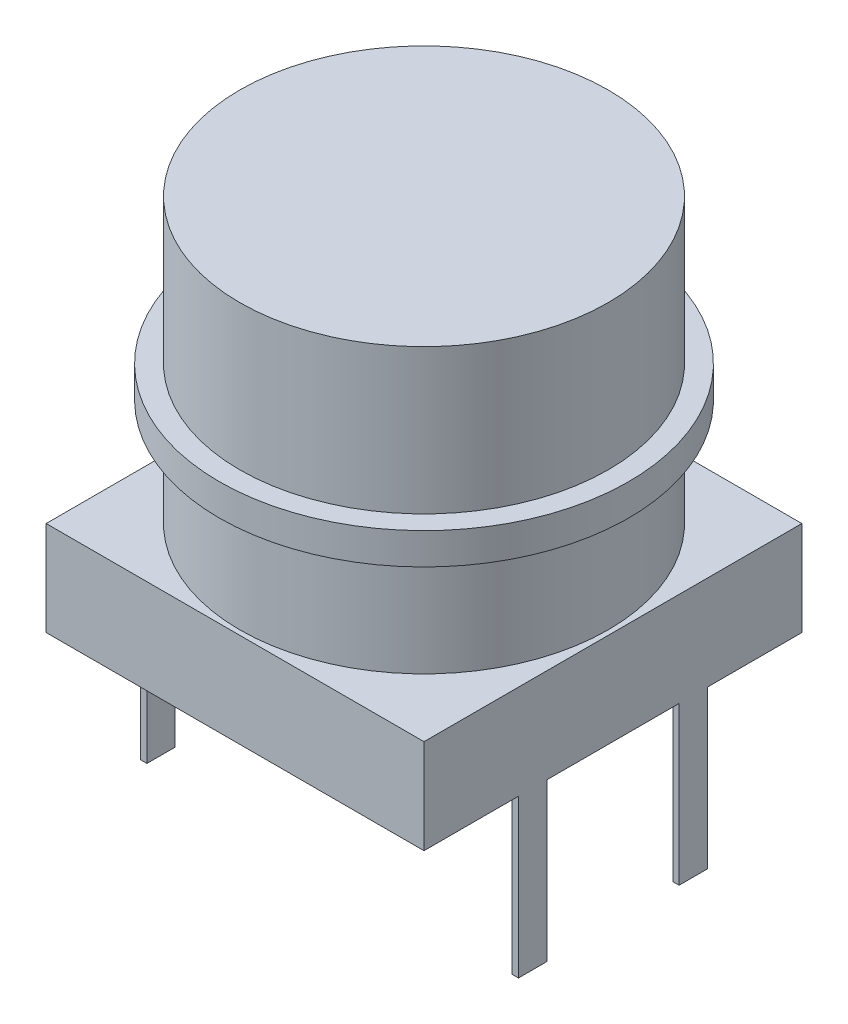
from build123d import *

# Parameters (mm, degrees)
SKETCH_1_W      = 12
SKETCH_1_H      = 12
EXTRUDE_1_DEPTH = 3
SKETCH_2_W      = 5
SKETCH_2_H      = 5
EXTRUDE_2_DEPTH = 3.4
SKETCH_3_R      = 6.5
EXTRUDE_3_DEPTH = 1
EXTRUDE_START   = -7.4
SKETCH_4_R      = 5.85
EXTRUDE_4_DEPTH = 12
SKETCH_5_W      = 0.2
SKETCH_5_H      = 0.9
EXTRUDE_5_DEPTH = 5


with BuildPart() as part:
    # 草图1 → 凸台-拉伸1 (new body)
    with BuildSketch(Plane(origin=(0, 0, 0), x_dir=(1, 0, 0), z_dir=(0, 1, 0))):
        Rectangle(SKETCH_1_W, SKETCH_1_H)
    extrude(amount=EXTRUDE_1_DEPTH)

    # 草图2 → 凸台-拉伸2 (add)
    with BuildSketch(Plane(origin=(0, 3, 0), x_dir=(1, 0, 0), z_dir=(0, 1, 0))):
        Rectangle(SKETCH_2_W, SKETCH_2_H)
    extrude(amount=EXTRUDE_2_DEPTH)

    # 草图3 → 凸台-拉伸3 (add)
    with BuildSketch(Plane(origin=(0, 6.4, 0), x_dir=(1, 0, 0), z_dir=(0, 1, 0))):
        Circle(SKETCH_3_R)
    extrude(amount=EXTRUDE_3_DEPTH)

    # 草图4 → 凸台-拉伸4 (add)
    with BuildSketch(Plane(origin=(0, 7.4, 0), x_dir=(1, 0, 0), z_dir=(0, 1, 0)).offset(EXTRUDE_START)):
        Circle(SKETCH_4_R)
    extrude(amount=EXTRUDE_4_DEPTH)

    # 草图5 → 凸台-拉伸5 (add)
    with BuildSketch(Plane.XZ):
        with Locations((5.9, 2.55)):
            Rectangle(SKETCH_5_W, SKETCH_5_H)
        with Locations((5.9, -2.55)):
            Rectangle(SKETCH_5_W, SKETCH_5_H)
        with Locations((-5.9, -2.55)):
            Rectangle(SKETCH_5_W, SKETCH_5_H)
        with Locations((-5.9, 2.55)):
            Rectangle(SKETCH_5_W, SKETCH_5_H)
    extrude(amount=EXTRUDE_5_DEPTH)


solid = part.part
